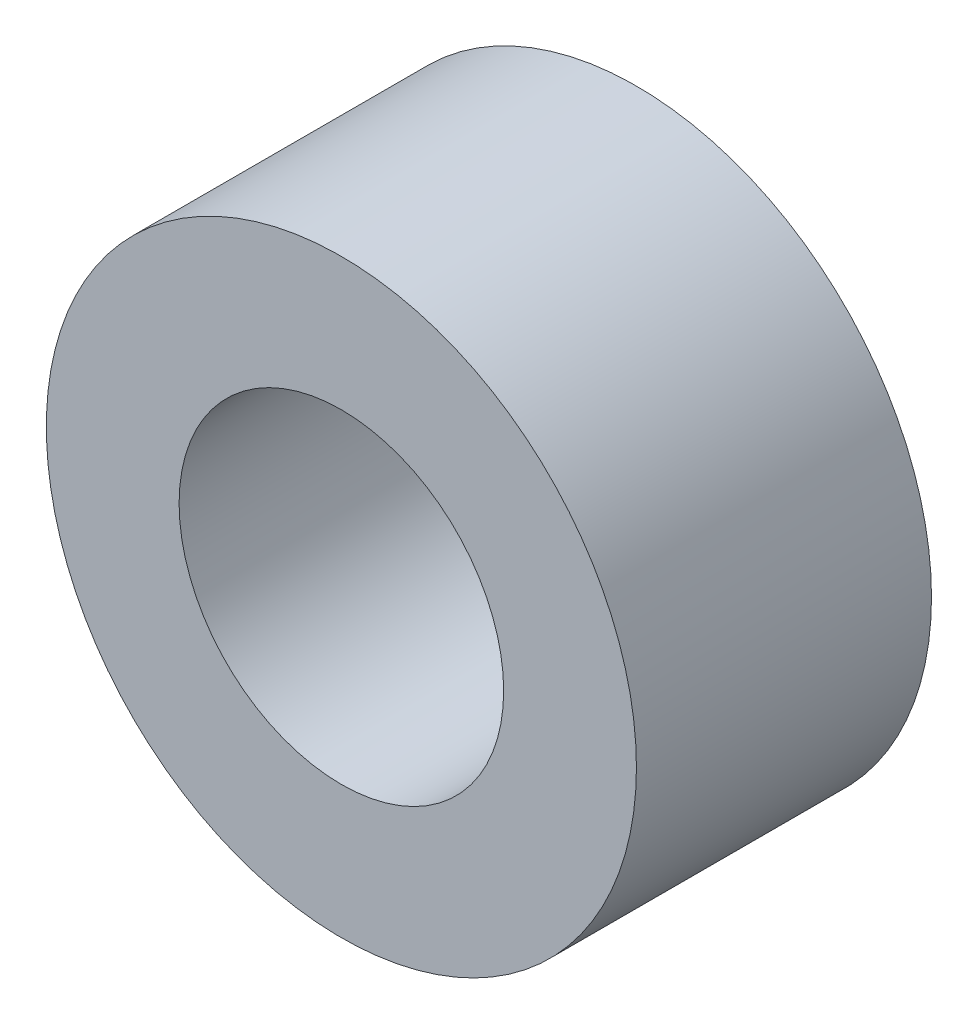
from build123d import *

# Parameters (mm, degrees)
ESQUISSE1_R        = 2
ESQUISSE1_R_2      = 1.1
BOSS_EXTRU_1_DEPTH = 2


with BuildPart() as part:
    # Esquisse1 → Boss.-Extru.1 (new body)
    with BuildSketch(Plane.XY):
        Circle(ESQUISSE1_R)
        Circle(ESQUISSE1_R_2, mode=Mode.SUBTRACT)
    extrude(amount=BOSS_EXTRU_1_DEPTH)


solid = part.part
